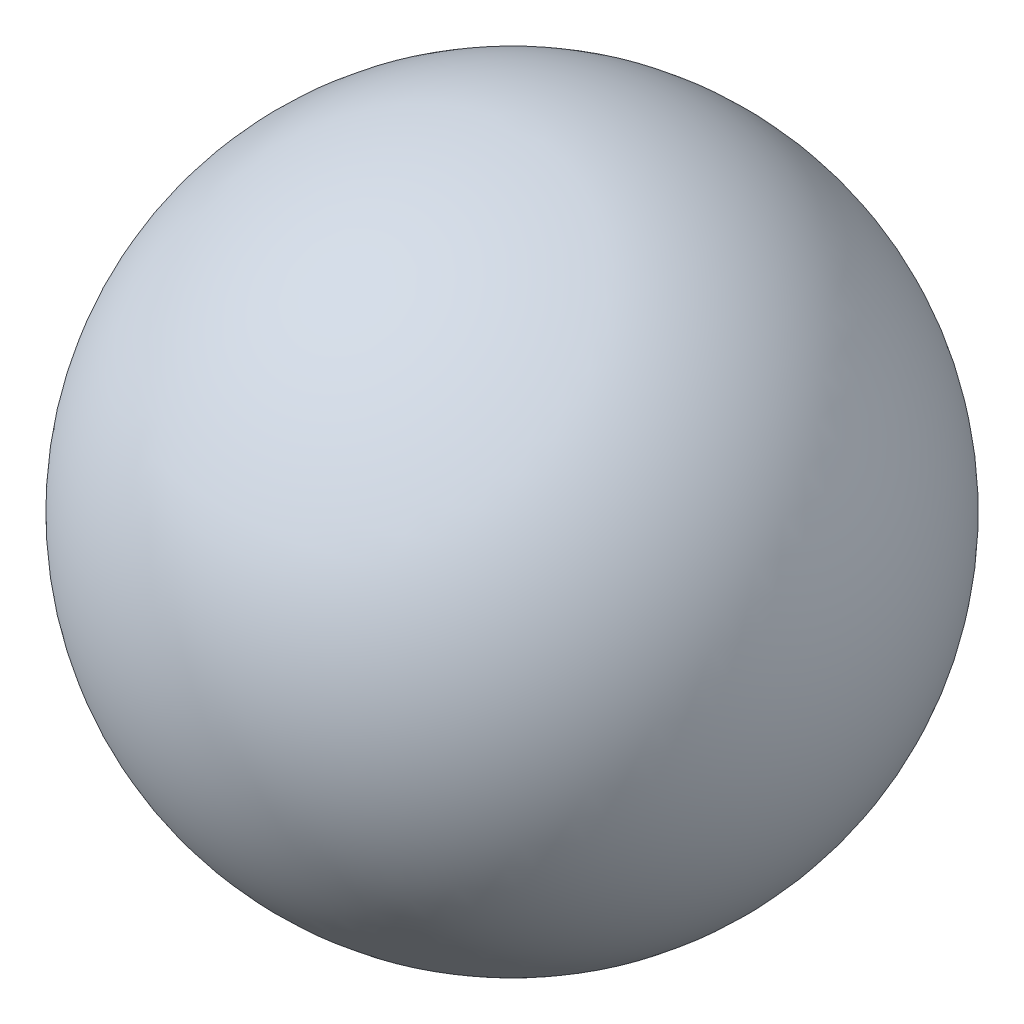
from build123d import *


with BuildPart() as part:
    # Sketch1 → Revolve1 (revolve)
    with BuildSketch(Plane.XY):
        with BuildLine():
            Line((0, 1.5), (0, 0))
            Line((0, 0), (0, -1.5))
            ThreePointArc((0, -1.5), (-1.5, 0), (0, 1.5))
        make_face()
    revolve(axis=Axis((0, 1.5, 0), (0, -1, 0)))


solid = part.part
